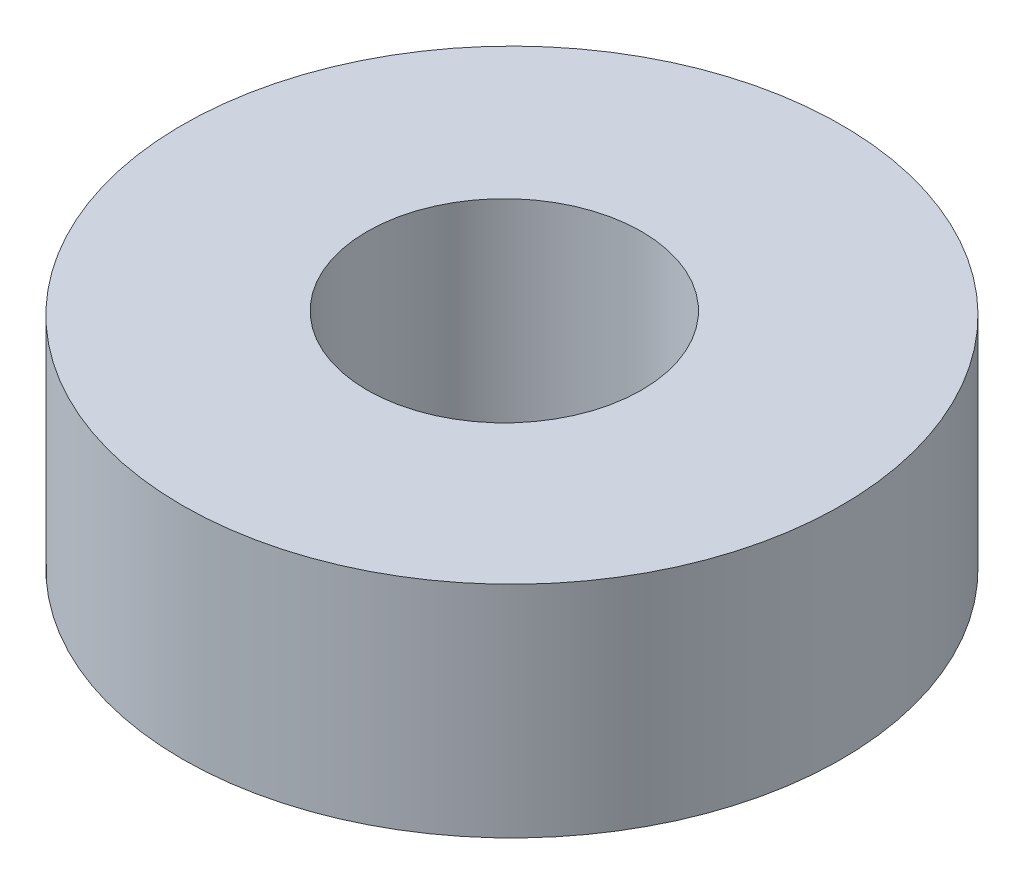
from build123d import *

# Parameters (mm, degrees)
SKETCH1_R           = 6
SKETCH1_R_2         = 2.5
BOSS_EXTRUDE1_DEPTH = 4


with BuildPart() as part:
    # Sketch1 → Boss-Extrude1 (new body)
    with BuildSketch(Plane(origin=(0, 0, 0), x_dir=(1, 0, 0), z_dir=(0, 1, 0))):
        with Locations((0.138632131, 0)):
            Circle(SKETCH1_R)
        Circle(SKETCH1_R_2, mode=Mode.SUBTRACT)
    extrude(amount=BOSS_EXTRUDE1_DEPTH)


solid = part.part
